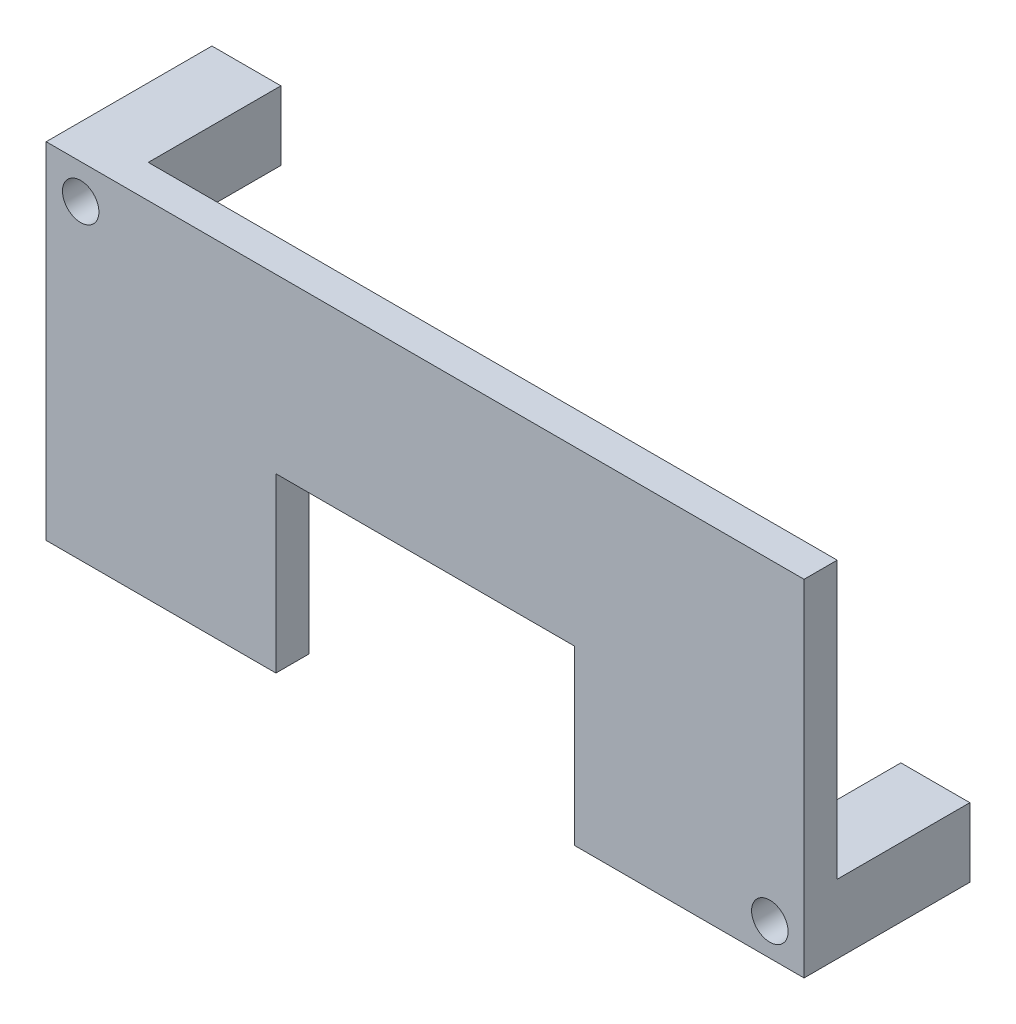
from build123d import *

# Parameters (mm, degrees)
SKIZZE1_W                       = 45.72
SKIZZE1_H                       = 20.83
AUFSATZ_LINEAR_AUSTRAGEN1_DEPTH = 2
SKIZZE3_W                       = 18
SKIZZE3_H                       = 10.415
SCHNITT_LINEAR_AUSTRAGEN1_DEPTH = 10
SKIZZE7_W                       = 4.16
SKIZZE7_H                       = 4.16
AUFSATZ_LINEAR_AUSTRAGEN2_DEPTH = 8
DURCHGANGSLOCH_F_R_M21_D        = 2.2


with BuildPart() as part:
    # Skizze1 → Aufsatz-Linear austragen1 (new body)
    with BuildSketch(Plane.XY):
        Rectangle(SKIZZE1_W, SKIZZE1_H)
    extrude(amount=AUFSATZ_LINEAR_AUSTRAGEN1_DEPTH)

    # Skizze3 → Schnitt-Linear austragen1 (cut)
    with BuildSketch(Plane(origin=(0, 0, 0), x_dir=(-1, 0, 0), z_dir=(0, 0, -1))):
        with Locations((0, -5.2075)):
            Rectangle(SKIZZE3_W, SKIZZE3_H)
    extrude(amount=-SCHNITT_LINEAR_AUSTRAGEN1_DEPTH, mode=Mode.SUBTRACT)

    # Skizze7 → Aufsatz-Linear austragen2 (add)
    with BuildSketch(Plane(origin=(0, 0, 0), x_dir=(-1, 0, 0), z_dir=(0, 0, -1))):
        with Locations((20.78, 8.335)):
            Rectangle(SKIZZE7_W, SKIZZE7_H)
        with Locations((-20.78, -8.335)):
            Rectangle(SKIZZE7_W, SKIZZE7_H)
    extrude(amount=AUFSATZ_LINEAR_AUSTRAGEN2_DEPTH)

    # Durchgangsloch für M21 (through all)
    with Locations(Plane(origin=(0, 0, -8), x_dir=(-1, 0, 0), z_dir=(0, 0, -1))):
        with Locations((-20.795475973, -8.476722081), (20.7772, 8.3322)):
            Hole(DURCHGANGSLOCH_F_R_M21_D / 2)


solid = part.part
